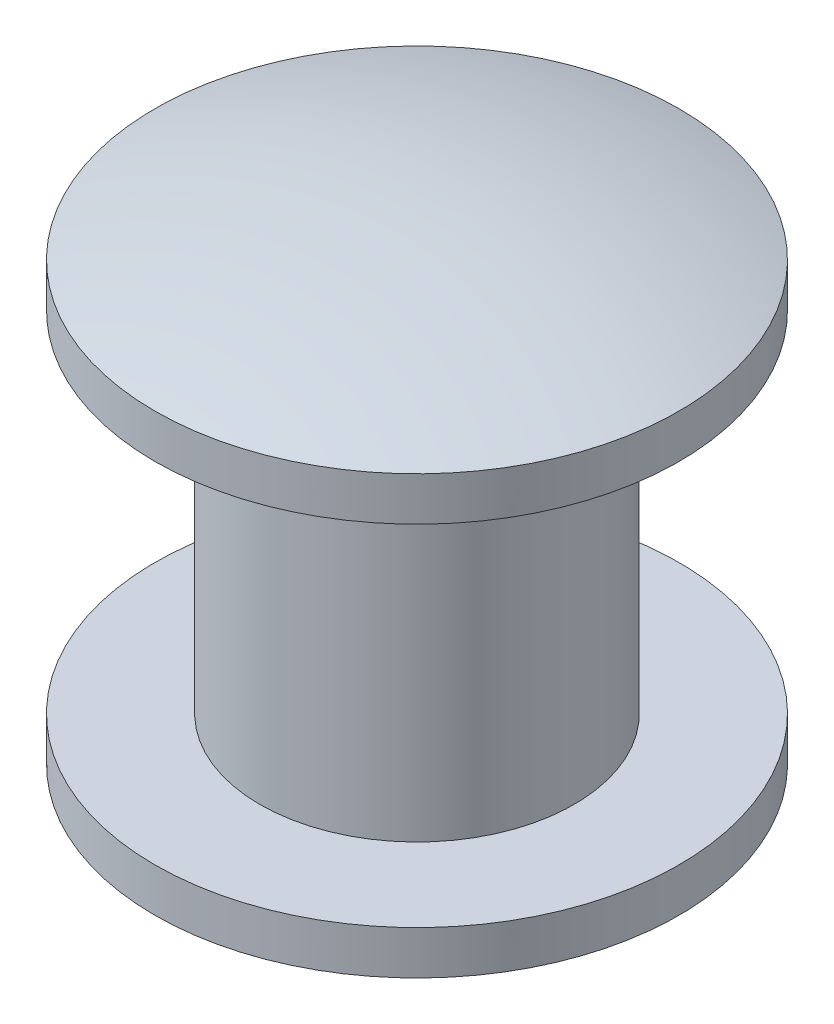
from build123d import *


with BuildPart() as part:
    # Sketch1 → Revolve1 (revolve)
    with BuildSketch(Plane(origin=(0, 0, 0), x_dir=(0, 0, -1), z_dir=(1, 0, 0))):
        with BuildLine():
            Line((0, 0), (0, -7.62))
            ThreePointArc((0, -7.62), (1.931277103, -7.46016262), (3.81, -6.985))
            Line((3.81, -6.985), (3.81, -6.35))
            Line((3.81, -6.35), (2.286, -6.35))
            Line((2.286, -6.35), (2.286, -1.27))
            Line((2.286, -1.27), (3.81, -1.27))
            Line((3.81, -1.27), (3.81, -0.635))
            ThreePointArc((3.81, -0.635), (1.931277103, -0.15983738), (0, 0))
        make_face()
    revolve(axis=Axis((0, 0, 0), (0, -1, 0)))


solid = part.part
